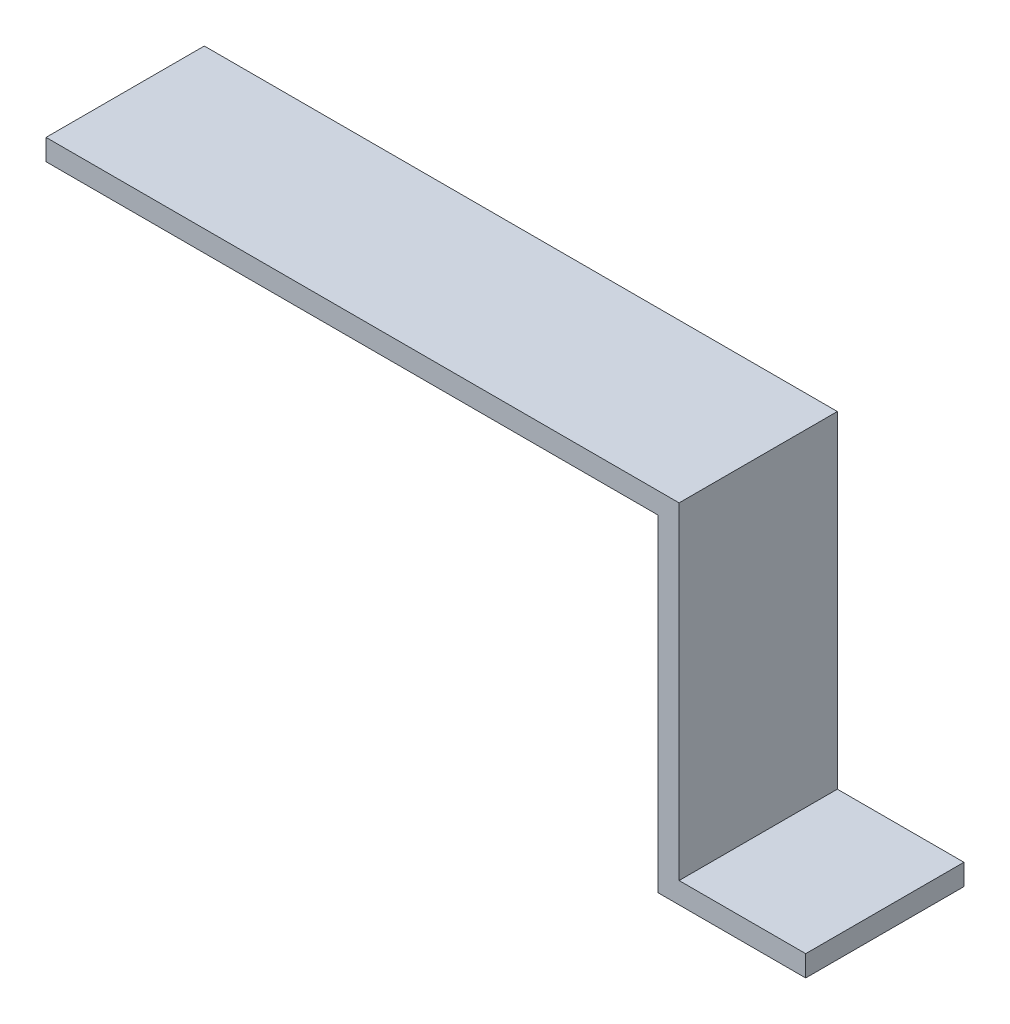
from build123d import *

# Parameters (mm, degrees)
AUFSATZ_LINEAR_AUSTRAGEN1_DEPTH = 15
SKIZZE4_W                       = 12.24
SKIZZE4_H                       = 15
SCHNITT_LINEAR_AUSTRAGEN1_DEPTH = 2


with BuildPart() as part:
    # Skizze2 → Aufsatz-Linear austragen1 (new body)
    with BuildSketch(Plane.XY):
        Polygon((0, 0), (60, 0), (60, -31), (84.23960897, -31), (84.23960897, -33), (58, -33), (58, -2), (0, -2), align=None)
    extrude(amount=AUFSATZ_LINEAR_AUSTRAGEN1_DEPTH)

    # Skizze4 → Schnitt-Linear austragen1 (cut)
    with BuildSketch(Plane(origin=(0, -31, 0), x_dir=(1, 0, 0), z_dir=(0, 1, 0))):
        with Locations((78.11960897, -7.5)):
            Rectangle(SKIZZE4_W, SKIZZE4_H)
    extrude(amount=-SCHNITT_LINEAR_AUSTRAGEN1_DEPTH, mode=Mode.SUBTRACT)


solid = part.part
